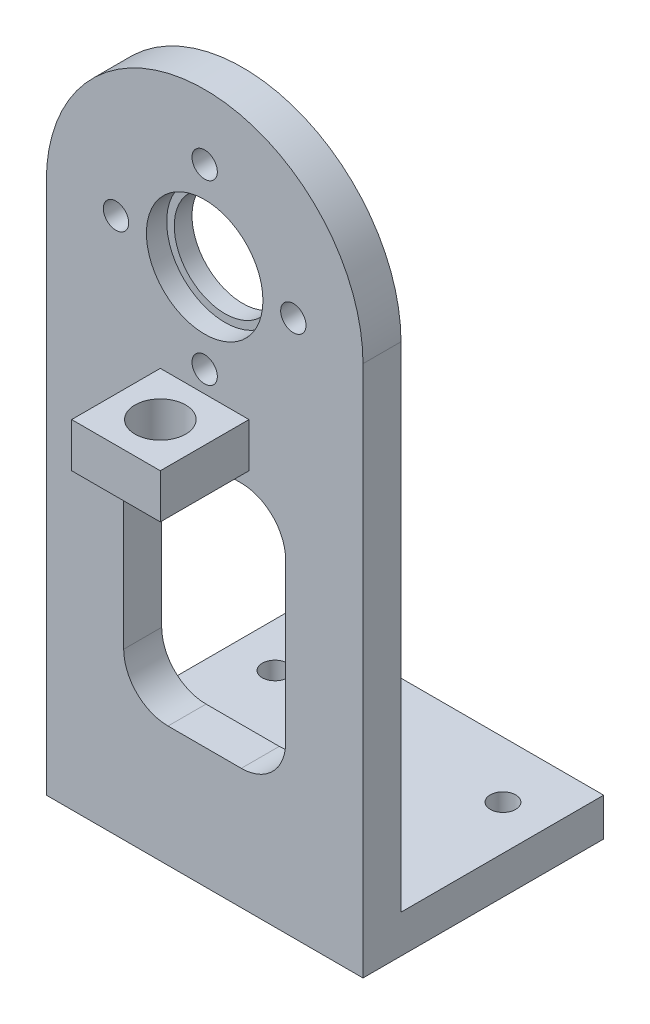
from build123d import *

# Parameters (mm, degrees)
SKETCH1_W           = 25
SKETCH1_H           = 38.558203604
SKETCH1_H_2         = 3.441796396
BOSS_EXTRUDE1_DEPTH = 3
SKETCH2_R           = 4
SKETCH2_R_2         = 1
CUT_EXTRUDE1_DEPTH  = 3
SKETCH4_R           = 4.6
CUT_EXTRUDE2_DEPTH  = 1.6
SKETCH5_W           = 25
SKETCH5_H           = 3
BOSS_EXTRUDE3_DEPTH = 19
SKETCH7_R           = 1
CUT_EXTRUDE4_DEPTH  = 4
SKETCH8_W           = 12.783853214
SKETCH8_H           = 19.5
CUT_EXTRUDE5_DEPTH  = 4
FILLET1_R           = 3.5
SKETCH9_W           = 7
SKETCH9_H           = 3.5
BOSS_EXTRUDE4_DEPTH = 7
SKETCH10_R          = 2
CUT_EXTRUDE6_DEPTH  = 7


with BuildPart() as part:
    # Sketch1 → Boss-Extrude1 (new body)
    with BuildSketch(Plane.XY):
        with Locations((0, 8.156339421)):
            Rectangle(SKETCH1_W, SKETCH1_H)
        with BuildLine():
            Line((-12.5, 27.435441223), (12.5, 27.435441223))
            ThreePointArc((12.5, 27.435441223), (0, 39.935441223), (-12.5, 27.435441223))
        make_face()
        with Locations((0, -12.843660579)):
            Rectangle(SKETCH1_W, SKETCH1_H_2)
    extrude(amount=BOSS_EXTRUDE1_DEPTH)

    # Sketch2 → Cut-Extrude1 (cut)
    with BuildSketch(Plane.XY.offset(3)):
        with Locations((0, 27.802049159)):
            Circle(SKETCH2_R)
        with Locations((0, 34.802049159)):
            Circle(SKETCH2_R_2)
        with Locations((7, 27.802049159)):
            Circle(SKETCH2_R_2)
        with Locations((0, 20.802049159)):
            Circle(SKETCH2_R_2)
        with Locations((-7, 27.802049159)):
            Circle(SKETCH2_R_2)
    extrude(amount=-CUT_EXTRUDE1_DEPTH, mode=Mode.SUBTRACT)

    # Sketch4 → Cut-Extrude2 (cut)
    with BuildSketch(Plane.XY.offset(3)):
        with Locations((0, 27.802049159)):
            Circle(SKETCH4_R)
    extrude(amount=-CUT_EXTRUDE2_DEPTH, mode=Mode.SUBTRACT)

    # Sketch5 → Boss-Extrude3 (add)
    with BuildSketch(Plane.XY.offset(3)):
        with Locations((0, -13.064558777)):
            Rectangle(SKETCH5_W, SKETCH5_H)
    extrude(amount=-BOSS_EXTRUDE3_DEPTH)

    # Sketch7 → Cut-Extrude4 (cut)
    with BuildSketch(Plane(origin=(0, -11.564558777, 0), x_dir=(1, 0, 0), z_dir=(0, 1, 0))):
        with Locations((9, 11.55)):
            Circle(SKETCH7_R)
        with Locations((-9, 11.55)):
            Circle(SKETCH7_R)
    extrude(amount=-CUT_EXTRUDE4_DEPTH, mode=Mode.SUBTRACT)

    # Sketch8 → Cut-Extrude5 (cut)
    with BuildSketch(Plane.XY.offset(3)):
        with Locations((0, 4.716978639)):
            Rectangle(SKETCH8_W, SKETCH8_H)
    extrude(amount=-CUT_EXTRUDE5_DEPTH, mode=Mode.SUBTRACT)

    # Fillet1
    fillet1_edges = [part.edges().sort_by_distance(p)[0] for p in [
        (6.391926607, 14.466978639, 1.5),
        (6.391926607, -5.033021361, 1.5),
        (-6.391926607, -5.033021361, 1.5),
        (-6.391926607, 14.466978639, 1.5),
    ]]
    fillet(fillet1_edges, radius=FILLET1_R)

    # Sketch9 → Boss-Extrude4 (add)
    with BuildSketch(Plane.XY.offset(3)):
        with Locations((0, 17.365441223)):
            Rectangle(SKETCH9_W, SKETCH9_H)
    extrude(amount=BOSS_EXTRUDE4_DEPTH)

    # Sketch10 → Cut-Extrude6 (cut)
    with BuildSketch(Plane(origin=(0, 19.115441223, 0), x_dir=(1, 0, 0), z_dir=(0, 1, 0))):
        with Locations((0, -6.5)):
            Circle(SKETCH10_R)
    extrude(amount=-CUT_EXTRUDE6_DEPTH, mode=Mode.SUBTRACT)


solid = part.part
